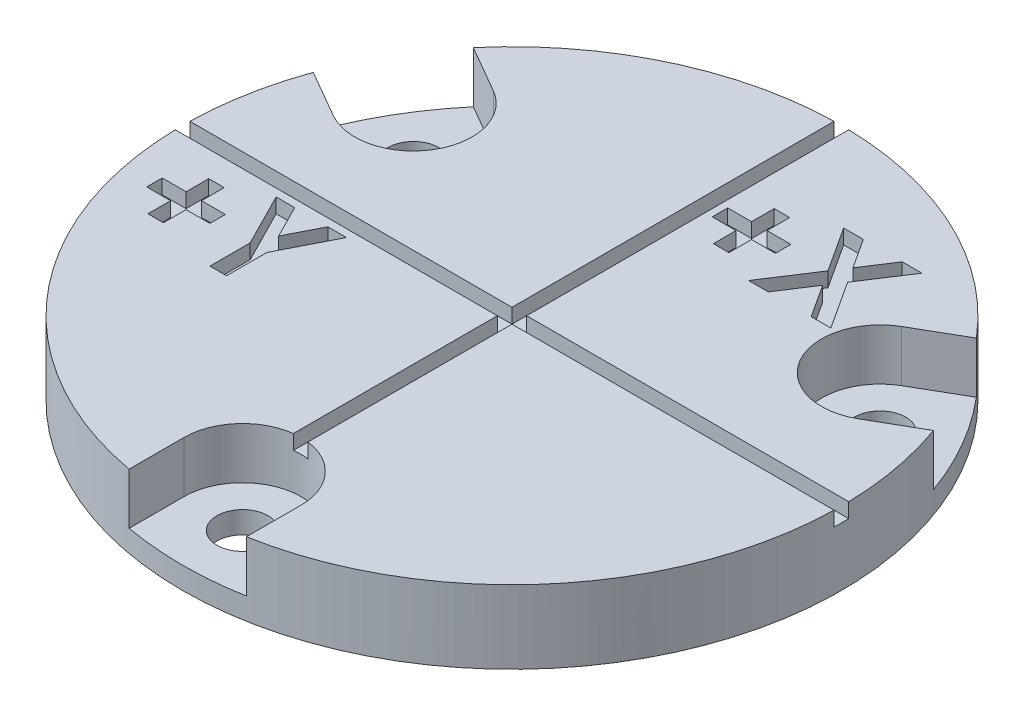
from build123d import *

# Parameters (mm, degrees)
SKETCH1_R               = 22.5
PLATE_DEPTH             = 5
OPENING_START           = 1.5
OPENING_FOR_SCREW_DEPTH = 5
SKETCH7_R               = 1.75
SCREW_HOLE_DEPTH        = 5
CIRPATTERN20_COUNT      = 3
SKETCH10_W              = 45
SKETCH10_H              = 1
SKETCH10_W_2            = 1
SKETCH10_H_2            = 45
CUT_EXTRUDE5_DEPTH      = 1
CUT_EXTRUDE6_DEPTH      = 1


with BuildPart() as part:
    # Sketch1 → plate (new body)
    with BuildSketch(Plane(origin=(0, 0, 0), x_dir=(1, 0, 0), z_dir=(0, 1, 0))):
        Circle(SKETCH1_R)
    extrude(amount=PLATE_DEPTH)

    # Sketch6 → opening for screw (cut)
    with BuildSketch(Plane(origin=(0, 5, 0), x_dir=(1, 0, 0), z_dir=(0, 1, 0)).offset(OPENING_START)):
        with BuildLine():
            Line((-4, -22.5), (-4, -18.4))
            ThreePointArc((-4, -18.4), (0, -14.4), (4, -18.4))
            Line((4, -18.4), (4, -22.5))
            ThreePointArc((4, -22.5), (0, -26.5), (-4, -22.5))
        make_face()
    opening_for_screw = extrude(amount=-OPENING_FOR_SCREW_DEPTH, mode=Mode.SUBTRACT)

    # Sketch7 → screw hole (cut)
    with BuildSketch(Plane(origin=(0, 1.5, 0), x_dir=(1, 0, 0), z_dir=(0, 1, 0))):
        with Locations((0, -18.4)):
            Circle(SKETCH7_R)
    screw_hole = extrude(amount=-SCREW_HOLE_DEPTH, mode=Mode.SUBTRACT)

    # CirPattern20: opening for screw, screw hole ×3 about axis
    cirpattern20_axis = Axis((0, 0, 0), (0, 1, 0))
    for i in range(1, CIRPATTERN20_COUNT):
        add(opening_for_screw.rotate(cirpattern20_axis, i * 360 / CIRPATTERN20_COUNT), mode=Mode.SUBTRACT)
        add(screw_hole.rotate(cirpattern20_axis, i * 360 / CIRPATTERN20_COUNT), mode=Mode.SUBTRACT)

    # Sketch10 → Cut-Extrude5 (cut)
    with BuildSketch(Plane(origin=(0, 5, 0), x_dir=(1, 0, 0), z_dir=(0, 1, 0))):
        Rectangle(SKETCH10_W, SKETCH10_H)
        Rectangle(SKETCH10_W_2, SKETCH10_H_2)
    extrude(amount=-CUT_EXTRUDE5_DEPTH, mode=Mode.SUBTRACT)

    # Sketch11 → Cut-Extrude6 (cut)
    with BuildSketch(Plane(origin=(0, 5, 0), x_dir=(1, 0, 0), z_dir=(0, 1, 0))):
        Polygon((2.616666667, 13.742425761), (2.616666667, 15.289220632), (3.675, 15.289220632), (3.675, 13.742425761), (5.303205128, 13.742425761), (5.303205128, 12.684092427), (3.675, 12.684092427), (3.675, 11.137297556), (2.616666667, 11.137297556), (2.616666667, 12.684092427), (0.988461538, 12.684092427), (0.988461538, 13.742425761), align=None)
        Polygon((6.136388221, 16.510374479), (7.479657452, 16.510374479), (8.806390224, 14.471301963), (10.135667067, 16.510374479), (11.480208333, 16.510374479), (9.47802484, 13.43968137), (11.6125, 10.160374479), (10.269230769, 10.160374479), (8.806390224, 12.409332812), (7.339733574, 10.160374479), (5.995192308, 10.160374479), (8.134755609, 13.440953405), align=None)
        Polygon((-18.458103671, -3.794817635), (-18.458103671, -2.248022763), (-17.399770338, -2.248022763), (-17.399770338, -3.794817635), (-15.771565209, -3.794817635), (-15.771565209, -4.853150968), (-17.399770338, -4.853150968), (-17.399770338, -6.39994584), (-18.458103671, -6.39994584), (-18.458103671, -4.853150968), (-20.086308799, -4.853150968), (-20.086308799, -3.794817635), align=None)
        Polygon((-15.07957803, -1.026868917), (-13.811358879, -1.026868917), (-12.677975466, -3.254202651), (-11.544592052, -1.026868917), (-10.276372902, -1.026868917), (-12.108103671, -4.626728693), (-12.108103671, -7.376868917), (-13.247847261, -7.376868917), (-13.247847261, -4.626728693), align=None)
    extrude(amount=-CUT_EXTRUDE6_DEPTH, mode=Mode.SUBTRACT)


solid = part.part
